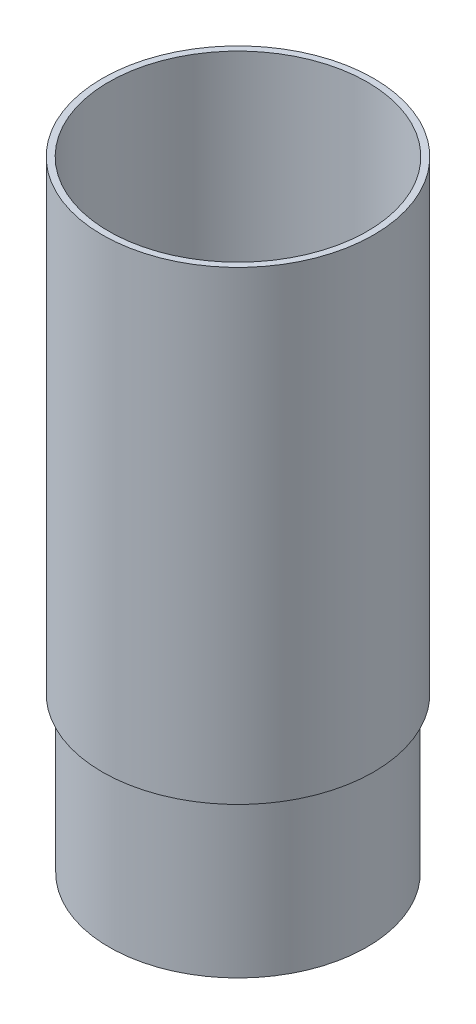
from build123d import *


with BuildPart() as part:
    # Sketch1 → Revolve1 (revolve)
    with BuildSketch(Plane.XY):
        Polygon((-20.0787, -6.858779284), (-20.0787, 20.444981856), (-21.1836, 24.568524793), (-21.1836, 94.741220716), (-22.225, 94.741220716), (-22.225, 18.541220716), (-21.1201, 18.541220716), (-21.1201, -6.858779284), align=None)
    revolve(axis=Axis((0, 0, 0), (0, 1, 0)))


solid = part.part
